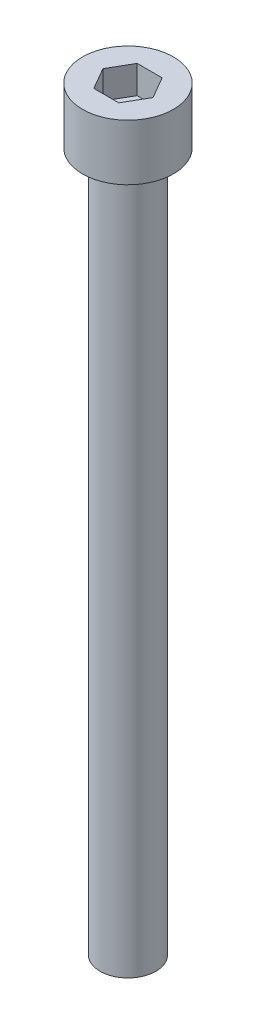
from build123d import *

# Parameters (mm, degrees)
SKETCH_1_R            = 6.5
EXTRUDE_248_DEPTH     = 8
CUT_EXTRUDE_382_DEPTH = 4
SKETCH_3_R            = 4
EXTRUDE_487_DEPTH     = 100


with BuildPart() as part:
    # 草图1 → Extrude 248 (new body)
    with BuildSketch(Plane(origin=(0, 0, 0), x_dir=(1, 0, 0), z_dir=(0, 1, 0))):
        Circle(SKETCH_1_R)
    extrude(amount=EXTRUDE_248_DEPTH)

    # 草图2 → Cut-Extrude 382 (cut)
    with BuildSketch(Plane(origin=(0, 8, 0), x_dir=(1, 0, 0), z_dir=(0, 1, 0))):
        Polygon((3.579571669, 0), (1.789785834, 3.1), (-1.789785834, 3.1), (-3.579571669, 0), (-1.789785834, -3.1), (1.789785834, -3.1), align=None)
    extrude(amount=-CUT_EXTRUDE_382_DEPTH, mode=Mode.SUBTRACT)

    # 草图3 → Extrude 487 (add)
    with BuildSketch(Plane.XZ):
        Circle(SKETCH_3_R)
    extrude(amount=EXTRUDE_487_DEPTH)


solid = part.part
